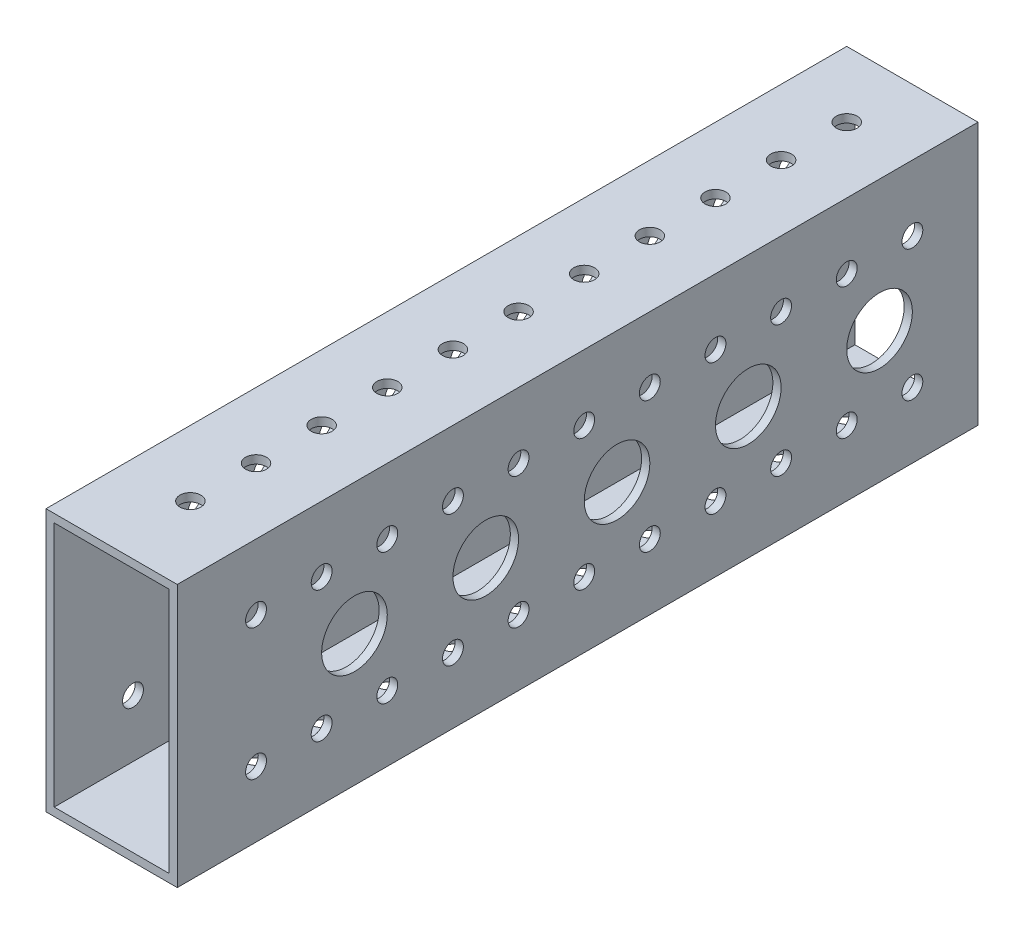
from build123d import *

# Parameters (mm, degrees)
SKETCH1_W                   = 25.4
SKETCH1_H                   = 50.8
BOSS_EXTRUDE1_DEPTH         = 154.94
SHELL1_T                    = -1.5875
F_21_0_159_DIAMETER_HOLE1_D = 4.0386
LPATTERN1_COUNT             = 11
LPATTERN1_PITCH             = 12.7
LPATTERN1_COUNT_DIR2        = 2
LPATTERN1_PITCH_DIR2        = 25.4
F_1_2_0_5_DIAMETER_HOLE1_D  = 12.7
LPATTERN2_COUNT             = 5
LPATTERN2_PITCH             = 25.4
F_21_0_159_DIAMETER_HOLE2_D = 4.0386
LPATTERN3_COUNT             = 11
LPATTERN3_PITCH             = 12.7


with BuildPart() as part:
    # Sketch1 → Boss-Extrude1 (new body)
    with BuildSketch(Plane.XY):
        with Locations((12.7, 25.4)):
            Rectangle(SKETCH1_W, SKETCH1_H)
    extrude(amount=BOSS_EXTRUDE1_DEPTH)

    # Shell1
    shell1_openings = [part.faces().sort_by_distance(p)[0] for p in [
        (12.7, 25.4, 154.94),
        (12.7, 25.4, 0),
    ]]
    offset(amount=SHELL1_T, openings=shell1_openings, kind=Kind.INTERSECTION)

    # #21 (0.159) Diameter Hole1 (through all)
    with Locations(Plane(origin=(25.4, 0, 0), x_dir=(0, 0, -1), z_dir=(1, 0, 0))):
        with Locations((-12.7, 38.1)):
            f_21_0_159_diameter_hole1 = Hole(F_21_0_159_DIAMETER_HOLE1_D / 2)

    # LPattern1: 21 _0.159_ Diameter Hole1 11 × 2
    with Locations(*[(0, -j * LPATTERN1_PITCH_DIR2, i * LPATTERN1_PITCH) for i in range(LPATTERN1_COUNT) for j in range(LPATTERN1_COUNT_DIR2) if (i, j) != (0, 0)]):
        add(f_21_0_159_diameter_hole1, mode=Mode.SUBTRACT)

    # 1/2 (0.5) Diameter Hole1 (through all)
    with Locations(Plane(origin=(25.4, 0, 0), x_dir=(0, 0, -1), z_dir=(1, 0, 0))):
        with Locations((-19.05, 25.4)):
            f_1_2_0_5_diameter_hole1 = Hole(F_1_2_0_5_DIAMETER_HOLE1_D / 2)

    # LPattern2: 1/2 (0.5) Diameter Hole1 ×5
    with Locations(*[(0, 0, i * LPATTERN2_PITCH) for i in range(1, LPATTERN2_COUNT)]):
        add(f_1_2_0_5_diameter_hole1, mode=Mode.SUBTRACT)

    # #21 (0.159) Diameter Hole2 (through all)
    with Locations(Plane(origin=(0, 50.8, 0), x_dir=(1, 0, 0), z_dir=(0, 1, 0))):
        with Locations((12.7, -12.7)):
            f_21_0_159_diameter_hole2 = Hole(F_21_0_159_DIAMETER_HOLE2_D / 2)

    # LPattern3: #21 (0.159) Diameter Hole2 ×11
    with Locations(*[(0, 0, i * LPATTERN3_PITCH) for i in range(1, LPATTERN3_COUNT)]):
        add(f_21_0_159_diameter_hole2, mode=Mode.SUBTRACT)


solid = part.part
